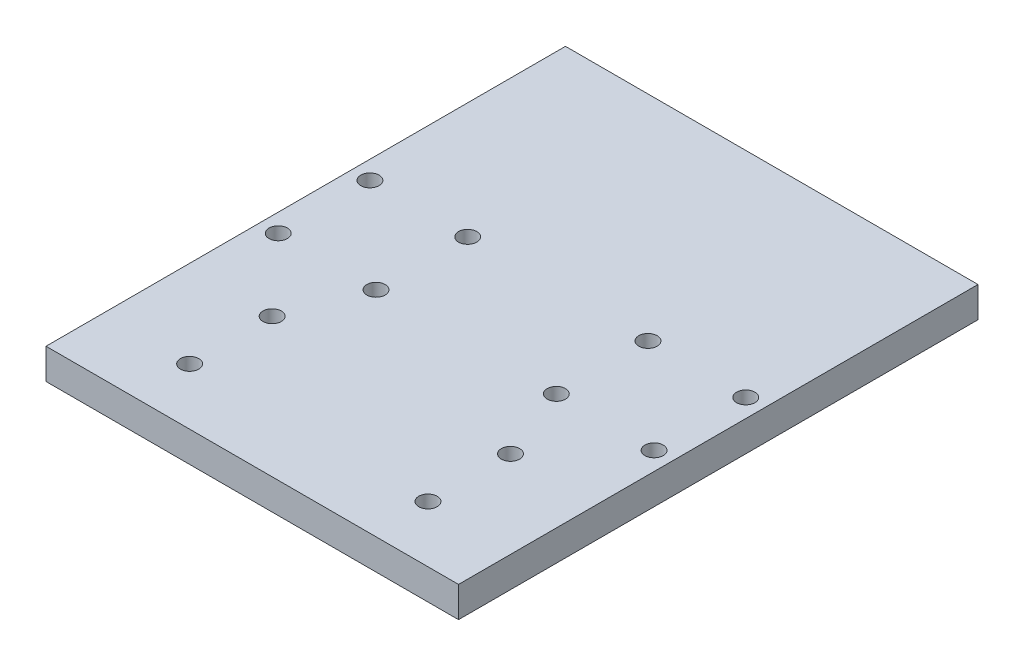
from build123d import *

# Parameters (mm, degrees)
SKETCH1_W           = 66
SKETCH1_H           = 85
BOSS_EXTRUDE1_DEPTH = 5
SKETCH4_R           = 1.5
CUT_EXTRUDE2_DEPTH  = 10
SKETCH8_W           = 85
SKETCH8_H           = 5
BOSS_EXTRUDE2_DEPTH = 0.75
SKETCH9_W           = 85
SKETCH9_H           = 5
BOSS_EXTRUDE3_DEPTH = 0.75
SKETCH10_R          = 1.5
CUT_EXTRUDE3_DEPTH  = 10


with BuildPart() as part:
    # Sketch1 → Boss-Extrude1 (new body)
    with BuildSketch(Plane(origin=(0, 0, 0), x_dir=(1, 0, 0), z_dir=(0, 1, 0))):
        Rectangle(SKETCH1_W, SKETCH1_H)
    extrude(amount=BOSS_EXTRUDE1_DEPTH)

    # Sketch4 → Cut-Extrude2 (cut)
    with BuildSketch(Plane(origin=(0, 5, 0), x_dir=(1, 0, 0), z_dir=(0, 1, 0))):
        with Locations((-30.75, 7.5)):
            Circle(SKETCH4_R)
        with Locations((-14.75, 7.5)):
            Circle(SKETCH4_R)
        with Locations((-30.75, -7.5)):
            Circle(SKETCH4_R)
        with Locations((-14.75, -7.5)):
            Circle(SKETCH4_R)
        with Locations((14.75, -7.5)):
            Circle(SKETCH4_R)
        with Locations((30.75, -7.5)):
            Circle(SKETCH4_R)
        with Locations((14.75, 7.5)):
            Circle(SKETCH4_R)
        with Locations((30.75, 7.5)):
            Circle(SKETCH4_R)
    extrude(amount=-CUT_EXTRUDE2_DEPTH, mode=Mode.SUBTRACT)

    # Sketch8 → Boss-Extrude2 (add)
    with BuildSketch(Plane.ZY.offset(33)):
        with Locations((0, 2.5)):
            Rectangle(SKETCH8_W, SKETCH8_H)
    extrude(amount=BOSS_EXTRUDE2_DEPTH)

    # Sketch9 → Boss-Extrude3 (add)
    with BuildSketch(Plane(origin=(33, 0, 0), x_dir=(0, 0, -1), z_dir=(1, 0, 0))):
        with Locations((0, 2.5)):
            Rectangle(SKETCH9_W, SKETCH9_H)
    extrude(amount=BOSS_EXTRUDE3_DEPTH)

    # Sketch10 → Cut-Extrude3 (cut)
    with BuildSketch(Plane(origin=(0, 5, 0), x_dir=(1, 0, 0), z_dir=(0, 1, 0))):
        with Locations((-19.5, -33.25)):
            Circle(SKETCH10_R)
        with Locations((-19.5, -19.75)):
            Circle(SKETCH10_R)
        with Locations((19.5, -33.25)):
            Circle(SKETCH10_R)
        with Locations((19.5, -19.75)):
            Circle(SKETCH10_R)
    extrude(amount=-CUT_EXTRUDE3_DEPTH, mode=Mode.SUBTRACT)


solid = part.part
